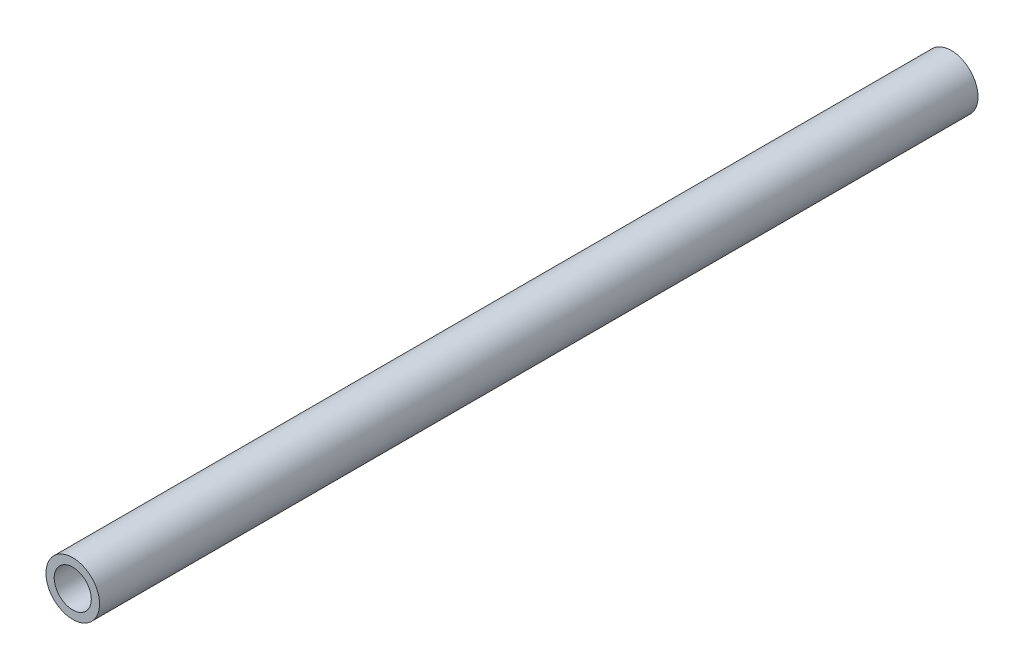
from build123d import *

# Parameters (mm, degrees)
SKETCH1_R           = 7.747
SKETCH1_R_2         = 5.3594
BOSS_EXTRUDE1_DEPTH = 254


with BuildPart() as part:
    # Sketch1 → Boss-Extrude1 (new body)
    with BuildSketch(Plane.XY):
        Circle(SKETCH1_R)
        Circle(SKETCH1_R_2, mode=Mode.SUBTRACT)
    extrude(amount=BOSS_EXTRUDE1_DEPTH)


solid = part.part
